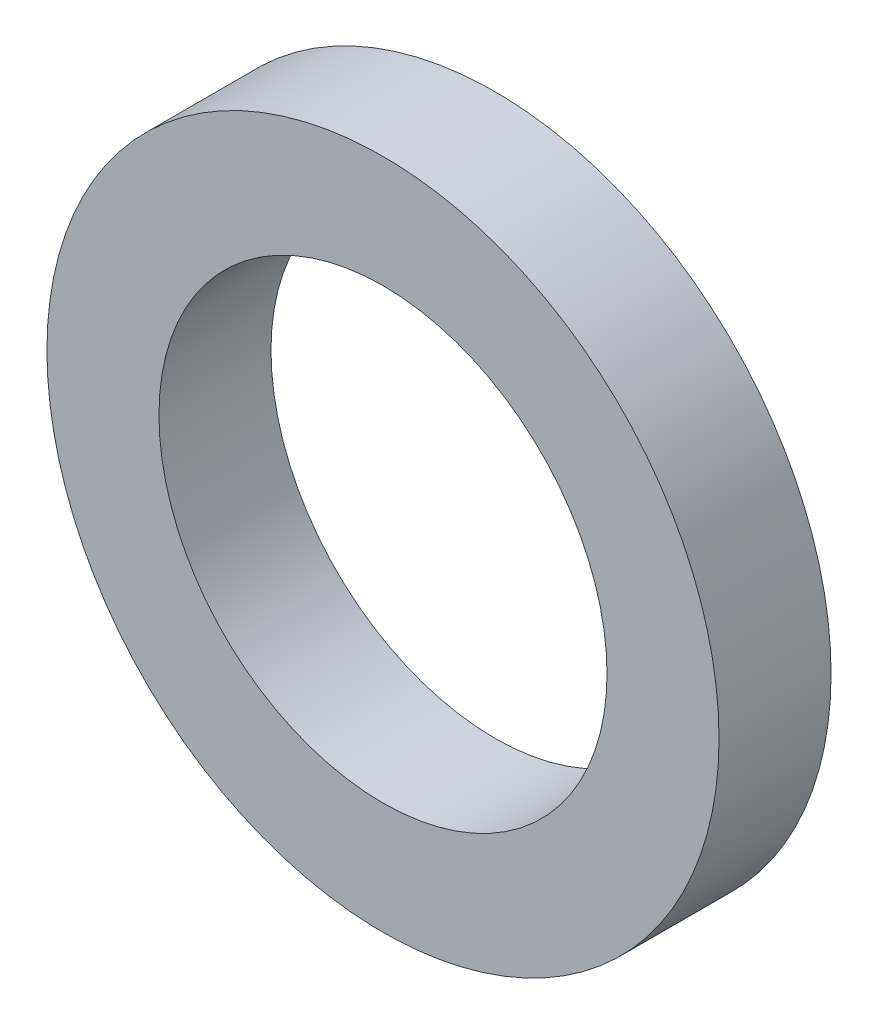
from build123d import *

# Parameters (mm, degrees)
ESQUISSE1_R      = 6
ESQUISSE1_R_2    = 4
EXTRUSION1_DEPTH = 2


with BuildPart() as part:
    # Esquisse1 → Extrusion1 (new body)
    with BuildSketch(Plane.XY):
        Circle(ESQUISSE1_R)
        Circle(ESQUISSE1_R_2, mode=Mode.SUBTRACT)
    extrude(amount=EXTRUSION1_DEPTH)


solid = part.part
